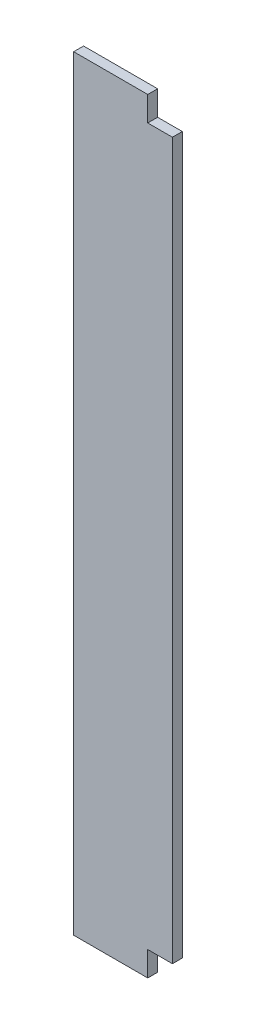
from build123d import *

# Parameters (mm, degrees)
ESBO_O1_W                = 200
ESBO_O1_H                = 20
RESSALTO_EXTRUS_O1_DEPTH = 1550
ESBO_O2_W                = 50
ESBO_O2_H                = 50
CORTE_EXTRUS_O1_DEPTH    = 21
ESBO_O3_W                = 50
ESBO_O3_H                = 50
CORTE_EXTRUS_O2_DEPTH    = 21


with BuildPart() as part:
    # Esboço1 → Ressalto-extrusão1 (new body)
    with BuildSketch(Plane(origin=(0, 0, 0), x_dir=(1, 0, 0), z_dir=(0, 1, 0))):
        with Locations((-29.608938547, 57.458100559)):
            Rectangle(ESBO_O1_W, ESBO_O1_H)
    extrude(amount=RESSALTO_EXTRUS_O1_DEPTH)

    # Esboço2 → Corte-extrusão1 (cut, through all)
    with BuildSketch(Plane.XY.offset(-47.458100559)):
        with Locations((45.391061453, 25)):
            Rectangle(ESBO_O2_W, ESBO_O2_H)
    extrude(amount=-CORTE_EXTRUS_O1_DEPTH, mode=Mode.SUBTRACT)

    # Esboço3 → Corte-extrusão2 (cut, through all)
    with BuildSketch(Plane.XY.offset(-47.458100559)):
        with Locations((45.391061453, 1525)):
            Rectangle(ESBO_O3_W, ESBO_O3_H)
    extrude(amount=-CORTE_EXTRUS_O2_DEPTH, mode=Mode.SUBTRACT)


solid = part.part
